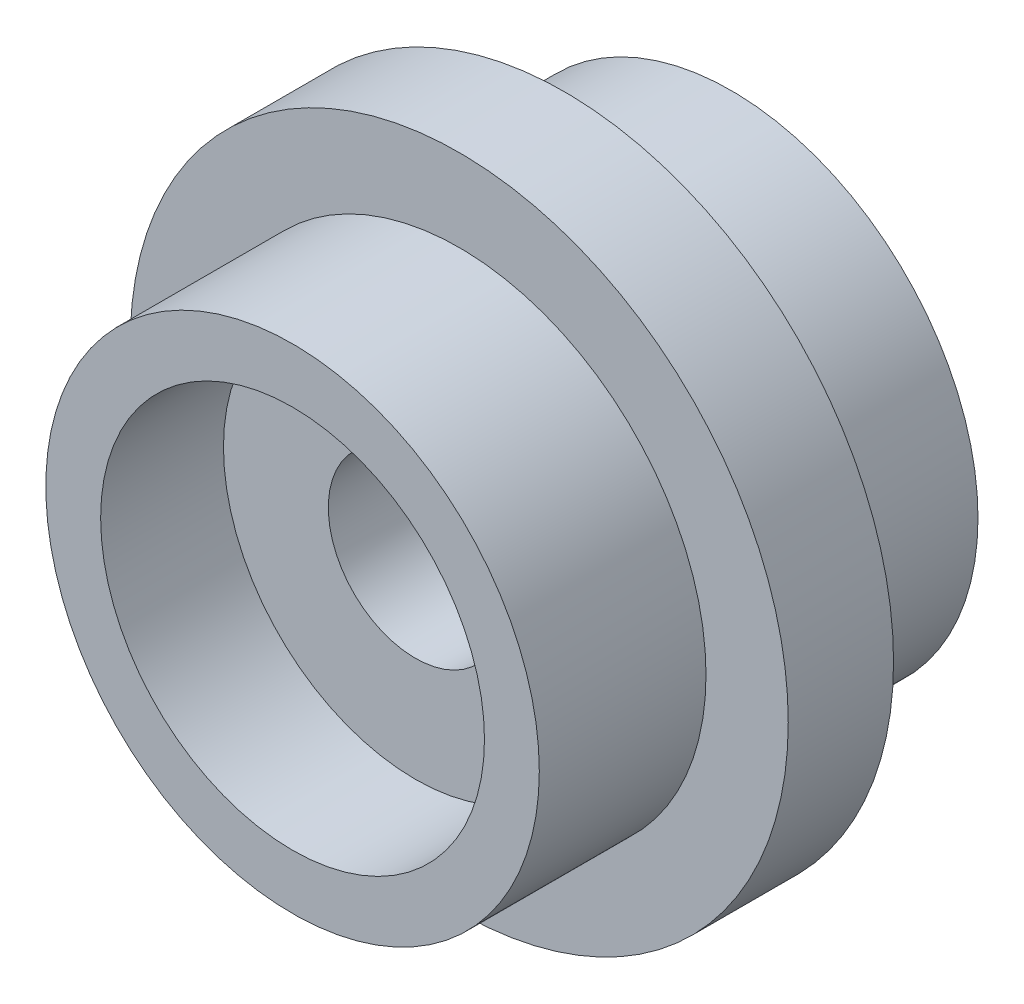
from build123d import *

# Parameters (mm, degrees)
F_3_8_CLEARANCE_HOLE1_D     = 10.0838
F_3_8_CLEARANCE_HOLE1_DEPTH = 25.4
SKETCH6_R                   = 11.1125
CUT_EXTRUDE1_DEPTH          = 7.112
SKETCH7_R                   = 11.1125
CUT_EXTRUDE2_DEPTH          = 12.065


with BuildPart() as part:
    # Sketch1 → Revolve1 (revolve)
    with BuildSketch(Plane(origin=(0, 0, 0), x_dir=(0, 0, -1), z_dir=(1, 0, 0))):
        Polygon((0, 0), (0, 14.2875), (9.652, 14.2875), (9.652, 19.05), (15.748, 19.05), (15.748, 14.2875), (25.4, 14.2875), (25.4, 0), align=None)
    revolve(axis=Axis((0, 0, 13.696708861), (0, 0, -1)))

    # 3/8 Clearance Hole1
    with Locations(Plane.XY):
        with Locations((0, 0)):
            Hole(F_3_8_CLEARANCE_HOLE1_D / 2, depth=F_3_8_CLEARANCE_HOLE1_DEPTH)

    # Sketch6 → Cut-Extrude1 (cut)
    with BuildSketch(Plane.XY):
        Circle(SKETCH6_R)
    extrude(amount=-CUT_EXTRUDE1_DEPTH, mode=Mode.SUBTRACT)

    # Sketch7 → Cut-Extrude2 (cut)
    with BuildSketch(Plane(origin=(0, 0, -25.4), x_dir=(-1, 0, 0), z_dir=(0, 0, -1))):
        Circle(SKETCH7_R)
    extrude(amount=-CUT_EXTRUDE2_DEPTH, mode=Mode.SUBTRACT)


solid = part.part
